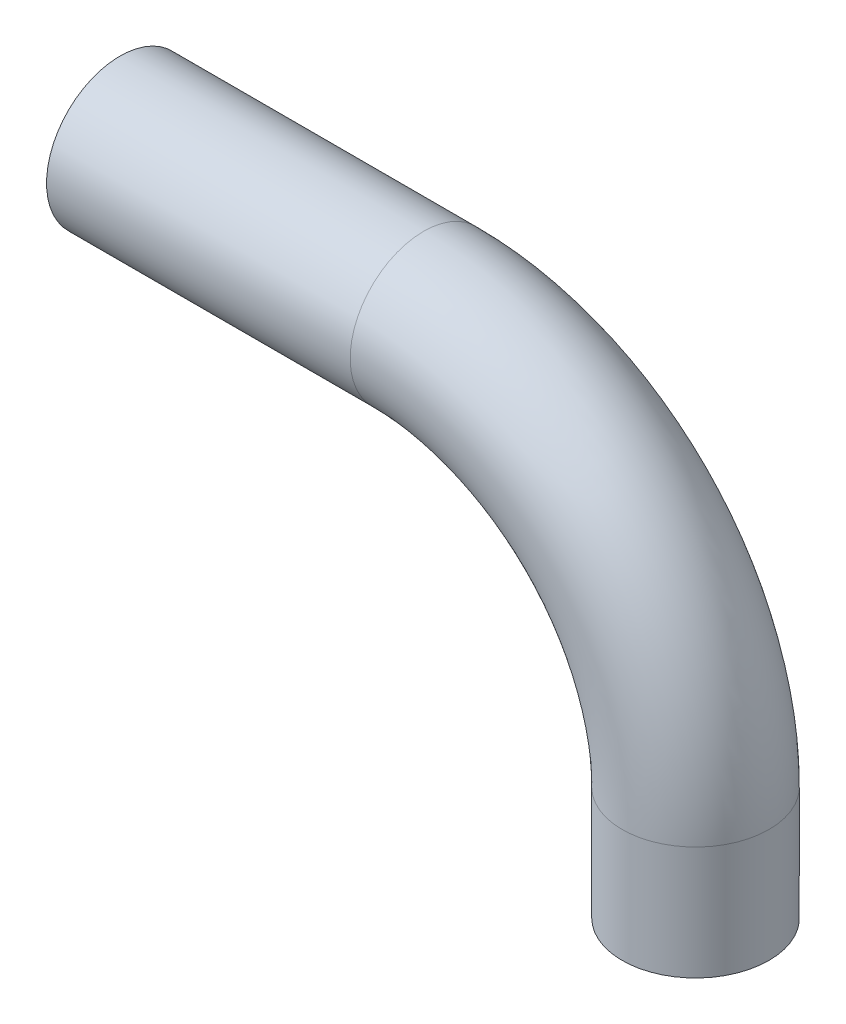
from build123d import *

# Parameters (mm, degrees)
SKETCH2_R = 13.5
SKETCH3_R = 13.1


with BuildPart() as part:
    # Sweep1: sweep along a path in Sketch1
    with BuildLine(Plane.XY) as sweep1_path:
        Line((0, 0), (55.82246027, 0))
        ThreePointArc((55.82246027, 0), (91.17779933, -14.644660941), (105.82246027, -50))
        Line((105.82246027, -50), (105.82246027, -70.851970701))
    # Sketch2 → Sweep1 (sweep)
    with BuildSketch(Plane(origin=(0, 0, 0), x_dir=(0, 0, -1), z_dir=(1, 0, 0))):
        Circle(SKETCH2_R)
    sweep(path=sweep1_path.line)

    # Cut-Sweep1: sweep along a path in Sketch1_2
    with BuildLine(Plane.XY) as cut_sweep1_path:
        Line((0, 0), (55.82246027, 0))
        ThreePointArc((55.82246027, 0), (91.17779933, -14.644660941), (105.82246027, -50))
        Line((105.82246027, -50), (105.82246027, -70.851970701))
    # Sketch3 → Cut-Sweep1 (sweep, cut)
    with BuildSketch(Plane.ZY):
        Circle(SKETCH3_R)
    sweep(path=cut_sweep1_path.line, mode=Mode.SUBTRACT)


solid = part.part
